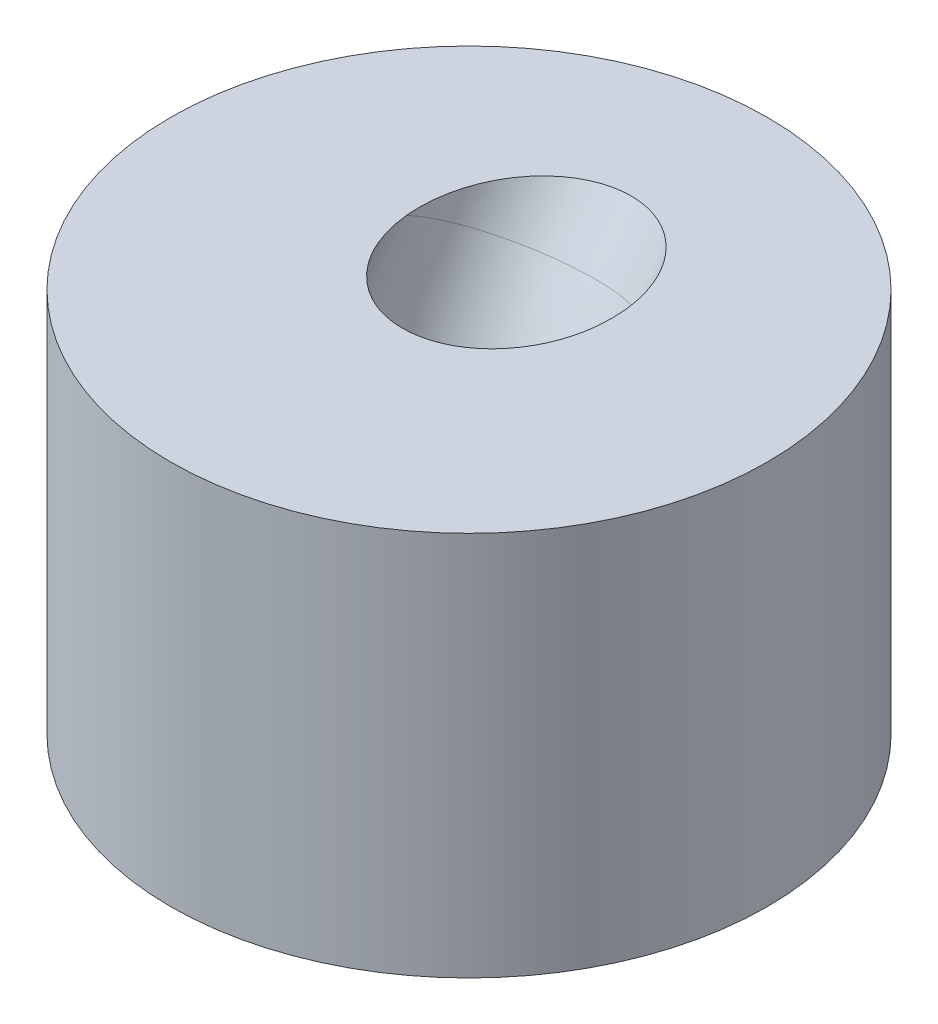
from build123d import *

# Parameters (mm, degrees)
SKETCH1_R           = 0.775
BOSS_EXTRUDE1_DEPTH = 1
SKETCH3_R           = 0.25


with BuildPart() as part:
    # Sketch1 → Boss-Extrude1 (new body)
    with BuildSketch(Plane(origin=(0, 0, 0), x_dir=(1, 0, 0), z_dir=(0, 1, 0))):
        Circle(SKETCH1_R)
    extrude(amount=BOSS_EXTRUDE1_DEPTH)

    # Cut-Sweep1: sweep along a path in Sketch2
    with BuildLine(Plane(origin=(0, 0, 0), x_dir=(0, 0, -1), z_dir=(1, 0, 0))) as cut_sweep1_path:
        Line((-0.222094233, -0.152695955), (-0.222094233, -0.128001882))
        ThreePointArc((-0.222094233, -0.128001882), (-0.135998837, 0.45248857), (0.114874932, 0.983001467))
        Line((0.114874932, 0.983001467), (0.338759746, 1.318128585))
    # Sketch3 → Cut-Sweep1 (sweep, cut)
    with BuildSketch(Plane.XZ):
        with Locations((0, 0.222094233)):
            Circle(SKETCH3_R)
    sweep(path=cut_sweep1_path.line, mode=Mode.SUBTRACT)


solid = part.part
